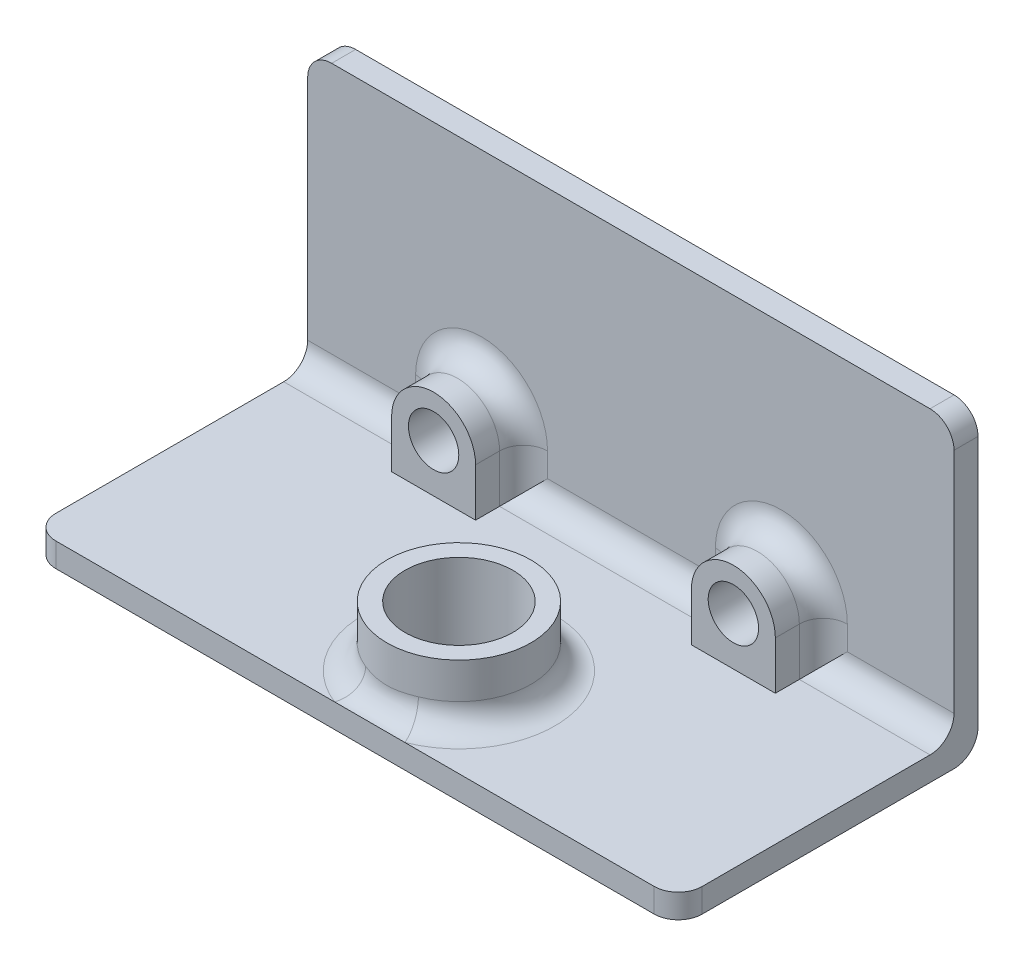
from build123d import *

# Parameters (mm, degrees)
SKETCH1_W           = 53.9
SKETCH1_H           = 25
BOSS_EXTRUDE1_DEPTH = 2
SKETCH2_W           = 53.9
SKETCH2_H           = 2
BOSS_EXTRUDE2_DEPTH = 23
SKETCH3_R           = 2.1
CUT_EXTRUDE1_DEPTH  = 3
SKETCH4_R           = 4.5
CUT_EXTRUDE2_DEPTH  = 3
SKETCH5_R           = 2.1
BOSS_EXTRUDE3_DEPTH = 4
SKETCH6_R           = 6
SKETCH6_R_2         = 4.5
BOSS_EXTRUDE4_DEPTH = 5
FILLET1_R           = 2


with BuildPart() as part:
    # Sketch1 → Boss-Extrude1 (new body)
    with BuildSketch(Plane.XY):
        with Locations((26.95, 12.5)):
            Rectangle(SKETCH1_W, SKETCH1_H)
    extrude(amount=BOSS_EXTRUDE1_DEPTH)

    # Sketch2 → Boss-Extrude2 (add)
    with BuildSketch(Plane.XY.offset(2)):
        with Locations((26.95, 1)):
            Rectangle(SKETCH2_W, SKETCH2_H)
    extrude(amount=BOSS_EXTRUDE2_DEPTH)

    # Sketch3 → Cut-Extrude1 (cut, through all)
    with BuildSketch(Plane.XY.offset(2)):
        with Locations((39.5, 6)):
            Circle(SKETCH3_R)
        with Locations((14.5, 6)):
            Circle(SKETCH3_R)
    extrude(amount=-CUT_EXTRUDE1_DEPTH, mode=Mode.SUBTRACT)

    # Sketch4 → Cut-Extrude2 (cut, through all)
    with BuildSketch(Plane(origin=(0, 2, 0), x_dir=(1, 0, 0), z_dir=(0, 1, 0))):
        with Locations((28.167949192, -17.557050808)):
            Circle(SKETCH4_R)
    extrude(amount=-CUT_EXTRUDE2_DEPTH, mode=Mode.SUBTRACT)

    # Sketch5 → Boss-Extrude3 (add)
    with BuildSketch(Plane.XY.offset(2)):
        with BuildLine():
            Line((18, 6), (18, 2))
            Line((18, 2), (11, 2))
            Line((11, 2), (11, 6))
            ThreePointArc((11, 6), (14.5, 9.5), (18, 6))
        make_face()
        with Locations((14.5, 6)):
            Circle(SKETCH5_R, mode=Mode.SUBTRACT)
        with BuildLine():
            Line((36, 6), (36, 2))
            Line((36, 2), (43, 2))
            Line((43, 2), (43, 6))
            ThreePointArc((43, 6), (39.5, 9.5), (36, 6))
        make_face()
        with Locations((39.5, 6)):
            Circle(SKETCH5_R, mode=Mode.SUBTRACT)
    extrude(amount=BOSS_EXTRUDE3_DEPTH)

    # Sketch6 → Boss-Extrude4 (add)
    with BuildSketch(Plane(origin=(0, 2, 0), x_dir=(1, 0, 0), z_dir=(0, 1, 0))):
        with Locations((28.167949192, -17.557050808)):
            Circle(SKETCH6_R)
        with Locations((28.167949192, -17.557050808)):
            Circle(SKETCH6_R_2, mode=Mode.SUBTRACT)
    extrude(amount=BOSS_EXTRUDE4_DEPTH)

    # Fillet1
    fillet1_edges = [part.edges().sort_by_distance(p)[0] for p in [
        (48.45, 2, 2),
        (0, 1, 25),
        (53.9, 1, 25),
        (5.5, 2, 2),
        (14.5, 9.5, 2),
        (11, 4, 2),
        (18, 4, 2),
        (27, 2, 2),
        (26.95, 0, 0),
        (39.5, 9.5, 2),
        (36, 4, 2),
        (43, 4, 2),
        (22.167949192, 2, 17.557050808),
        (0, 25, 1),
        (53.9, 25, 1),
    ]]
    fillet(fillet1_edges, radius=FILLET1_R)


solid = part.part
